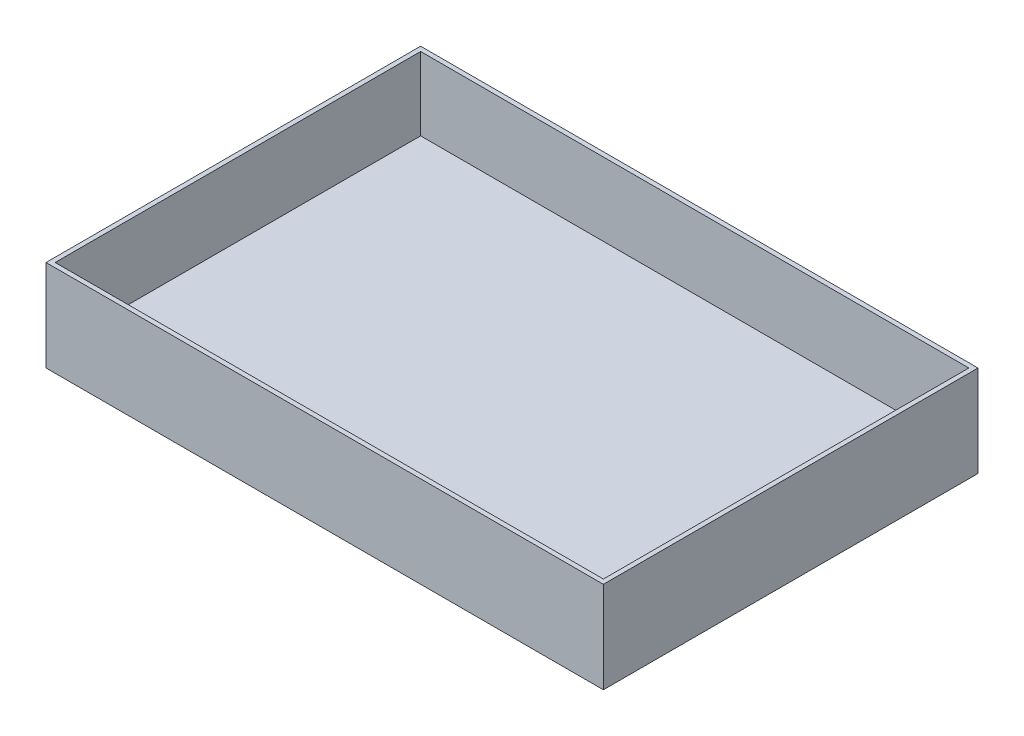
from build123d import *

# Parameters (mm, degrees)
ESBO_O4_W                = 61
ESBO_O4_H                = 41
RESSALTO_EXTRUS_O1_DEPTH = 10
ESBO_O5_W                = 60
ESBO_O5_H                = 40
CORTE_EXTRUS_O1_DEPTH    = 8


with BuildPart() as part:
    # Esboço4 → Ressalto-extrusão1 (new body)
    with BuildSketch(Plane(origin=(0, 0, 0), x_dir=(1, 0, 0), z_dir=(0, 1, 0))):
        Rectangle(ESBO_O4_W, ESBO_O4_H)
    extrude(amount=RESSALTO_EXTRUS_O1_DEPTH)

    # Esboço5 → Corte-extrusão1 (cut)
    with BuildSketch(Plane(origin=(0, 10, 0), x_dir=(1, 0, 0), z_dir=(0, 1, 0))):
        Rectangle(ESBO_O5_W, ESBO_O5_H)
    extrude(amount=-CORTE_EXTRUS_O1_DEPTH, mode=Mode.SUBTRACT)


solid = part.part
